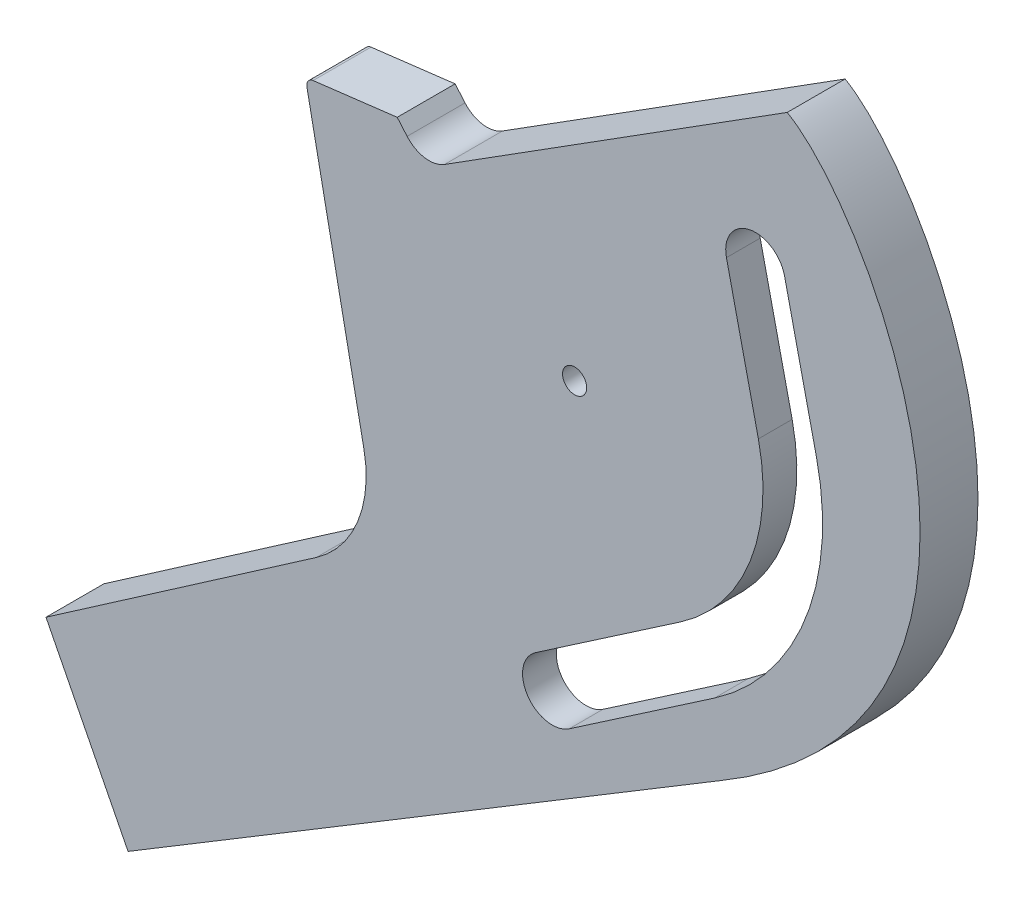
from build123d import *

# Parameters (mm, degrees)
SKETCH1_R           = 2.5
BOSS_EXTRUDE1_DEPTH = 12
CUT_EXTRUDE2_DEPTH  = 5
SKETCH2_R           = 20.406966807
SKETCH2_R_2         = 18.406966807
CUT_EXTRUDE1_DEPTH  = 5


with BuildPart() as part:
    # Sketch1 → Boss-Extrude1 (new body)
    with BuildSketch(Plane.XY):
        with BuildLine():
            Line((-26.955627075, 25.359398414), (44.050751749, 70.198338512))
            add(Edge.make_bspline(
                [(44.050751749, 70.198338512), (62.087157858, 60.129124735), (102.236821697, -14.309839041), (30.255220871, -56.610877482)],
                knots=[0, 0, 0, 0, 1, 1, 1, 1], degree=3))
            Line((30.255220871, -56.610877482), (-92.542495842, -130.724182913))
            Line((-92.542495842, -130.724182913), (-109.546280871, -97.192243206))
            Line((-109.546280871, -97.192243206), (-53.551819625, -58.475967995))
            ThreePointArc((-53.551819625, -58.475967995), (-44.950344781, -47.729789478), (-43.667906214, -34.025006607))
            Line((-43.667906214, -34.025006607), (-55.484471769, 25.012678553))
            ThreePointArc((-55.484471769, 25.012678553), (-55.229156607, 26.186005417), (-54.194896814, 26.796077907))
            Line((-54.194896814, 26.796077907), (-36.765460017, 28.917713338))
            Line((-36.765460017, 28.917713338), (-34.712668517, 26.525380142))
            ThreePointArc((-34.712668517, 26.525380142), (-31.051074716, 24.4992182), (-26.955627075, 25.359398414))
        make_face()
        Circle(SKETCH1_R, mode=Mode.SUBTRACT)
        with BuildLine():
            Line((38.077539086, 8.627342387), (31.457970773, 37.843392922))
            ThreePointArc((31.457970773, 37.843392922), (36.113405951, 45.226418252), (43.49643128, 40.570983074))
            Line((43.49643128, 40.570983074), (50.115999593, 11.354932539))
            ThreePointArc((50.115999593, 11.354932539), (47.829544092, -18.785170217), (28.993629861, -42.425432651))
            Line((28.993629861, -42.425432651), (-1.139071825, -63.018184329))
            ThreePointArc((-1.139071825, -63.018184329), (-9.716926906, -61.404944758), (-8.103687335, -52.827089677))
            Line((-8.103687335, -52.827089677), (22.029014352, -32.234337999))
            ThreePointArc((22.029014352, -32.234337999), (36.340317452, -14.272748403), (38.077539086, 8.627342387))
        make_face(mode=Mode.SUBTRACT)
    extrude(amount=-BOSS_EXTRUDE1_DEPTH)

    # Sketch3 → Cut-Extrude2 (cut)
    with BuildSketch(Plane(origin=(0, 0, -12), x_dir=(-1, 0, 0), z_dir=(0, 0, -1))):
        with BuildLine():
            Line((108.633361408, -98.992545924), (93.449492386, -128.935560359))
            Line((93.449492386, -128.935560359), (91.732523821, -127.89930155))
            Line((91.732523821, -127.89930155), (-29.231808811, -54.892516323))
            add(Edge.make_bspline(
                [(-44.065734477, 67.842412696), (-44.711989199, 67.409412256), (-45.319058391, 66.940521732), (-46.487121265, 65.960540056), (-47.04734625, 65.448744854), (-48.676831708, 63.866474713), (-49.695652132, 62.74980166), (-51.643061578, 60.433812481), (-52.570637695, 59.233568633), (-54.351661803, 56.76518688), (-55.206220539, 55.494184071), (-57.642169465, 51.637395526), (-59.108475151, 48.994377471), (-61.772216068, 43.585851359), (-62.968525898, 40.819830599), (-64.562191776, 36.579321004), (-65.059713989, 35.150465126), (-65.753925807, 32.983458962), (-65.976639631, 32.257164595), (-66.404295719, 30.796479627), (-66.609516748, 30.060994816), (-67.585549406, 26.379930292), (-68.207997329, 23.421535241), (-69.124162601, 17.476634327), (-69.417856055, 14.49012642), (-69.647875237, 8.486550939), (-69.584312973, 5.469492942), (-69.186185446, 0.918013899), (-69.001954276, -0.606436507), (-68.53395704, -3.614530288), (-68.249900615, -5.10403396), (-67.246805131, -9.528696616), (-66.377032654, -12.420063251), (-64.763908669, -16.667495261), (-64.174739481, -18.06835499), (-63.212508348, -20.146844678), (-62.87805617, -20.837039742), (-62.187699389, -22.200245629), (-61.831475952, -22.874060854), (-59.996492333, -26.20515645), (-58.3564207, -28.748698204), (-54.76187252, -33.614098874), (-52.807325031, -35.935907769), (-49.657387027, -39.264829798), (-48.576129174, -40.343226595), (-46.36681057, -42.431345516), (-45.23699415, -43.442927339), (-39.471767159, -48.350894333), (-34.491238963, -51.801735421), (-29.231808811, -54.892516323)],
                knots=[0, 0, 0, 0, 0.015625, 0.015625, 0.03125, 0.03125, 0.0625, 0.0625, 0.09375, 0.09375, 0.125, 0.125, 0.1875, 0.1875, 0.25, 0.25, 0.28125, 0.28125, 0.296875, 0.296875, 0.3125, 0.3125, 0.375, 0.375, 0.4375, 0.4375, 0.5, 0.5, 0.53125, 0.53125, 0.5625, 0.5625, 0.625, 0.625, 0.65625, 0.65625, 0.671875, 0.671875, 0.6875, 0.6875, 0.75, 0.75, 0.8125, 0.8125, 0.84375, 0.84375, 0.875, 0.875, 1, 1, 1, 1], degree=3))
            Line((-44.065734477, 67.842412696), (25.887763568, 23.668343261))
            ThreePointArc((25.887763568, 23.668343261), (31.348360423, 22.521436309), (36.230485491, 25.222985565))
            Line((36.230485491, 25.222985565), (37.586279366, 26.80303434))
            Line((37.586279366, 26.80303434), (53.417437888, 24.875952746))
            Line((53.417437888, 24.875952746), (41.706802558, -33.632485968))
            ThreePointArc((41.706802558, -33.632485968), (43.096111006, -48.479334078), (52.414375421, -60.121027471))
            Line((52.414375421, -60.121027471), (106.973050581, -97.844556472))
            Line((106.973050581, -97.844556472), (108.633361408, -98.992545924))
        make_face()
    extrude(amount=-CUT_EXTRUDE2_DEPTH, mode=Mode.SUBTRACT)

    # Sketch2 → Cut-Extrude1 (cut)
    with BuildSketch(Plane(origin=(0, 0, -7), x_dir=(-1, 0, 0), z_dir=(0, 0, -1))):
        Circle(SKETCH2_R)
        Circle(SKETCH2_R_2, mode=Mode.SUBTRACT)
    extrude(amount=-CUT_EXTRUDE1_DEPTH, mode=Mode.SUBTRACT)


solid = part.part
